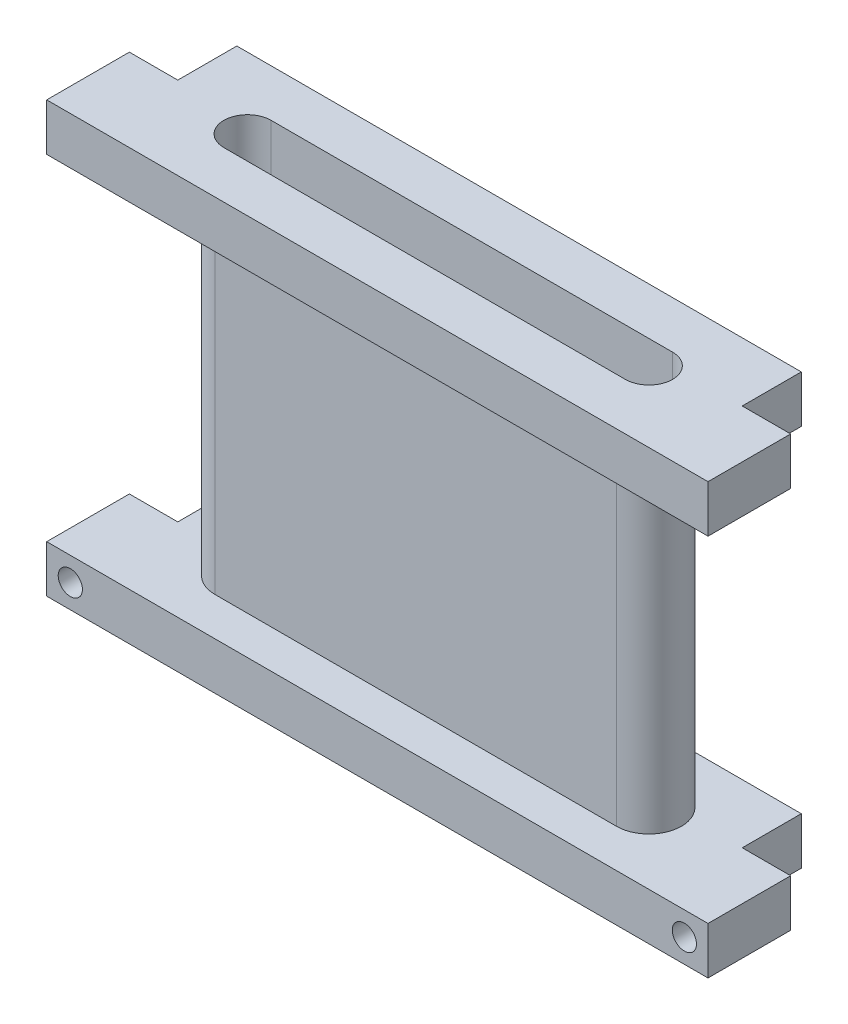
from build123d import *

# Parameters (mm, degrees)
SKETCH1_W                        = 56
SKETCH1_H                        = 8.750000002
BOSS_EXTRUDE1_DEPTH              = 4
BOSS_EXTRUDE2_DEPTH              = 28.4
SKETCH3_W                        = 56
SKETCH3_H                        = 12
BOSS_EXTRUDE3_DEPTH              = 4
SKETCH4_W                        = 56
SKETCH4_H                        = 4
BOSS_EXTRUDE4_DEPTH              = 3.249999998
CUT_EXTRUDE1_REACH               = 38.4
SKETCH5_W                        = 4.100000004
SKETCH5_H                        = 5
CUT_EXTRUDE2_REACH               = 38.4
SKETCH6_W                        = 4.100000004
SKETCH6_H                        = 5.000000001
SKETCH7_W                        = 4.100000004
SKETCH7_H                        = 5.000000001
CUT_EXTRUDE3_DEPTH               = 37.4
SKETCH8_W                        = 4.100000004
SKETCH8_H                        = 5
CUT_EXTRUDE4_DEPTH               = 37.4
CUT_EXTRUDE5_DEPTH               = 37.4
F_2_05_2_05_DIAMETER_HOLE1_D     = 2.05
F_2_05_2_05_DIAMETER_HOLE1_DEPTH = 4
F_2_05_2_05_DIAMETER_HOLE1_TIP   = 0.615882135


with BuildPart() as part:
    # Sketch1 → Boss-Extrude1 (new body)
    with BuildSketch(Plane(origin=(0, 0, 0), x_dir=(1, 0, 0), z_dir=(0, 1, 0))):
        with Locations((0, 1.624999999)):
            Rectangle(SKETCH1_W, SKETCH1_H)
    extrude(amount=-BOSS_EXTRUDE1_DEPTH)

    # Sketch2 → Boss-Extrude2 (add)
    with BuildSketch(Plane(origin=(0, 0, 0), x_dir=(-1, 0, 0), z_dir=(0, 1, 0))):
        with BuildLine():
            Line((-17, 2.75), (17, 2.75))
            ThreePointArc((17, 2.75), (19.75, 0), (17, -2.75))
            Line((17, -2.75), (-17, -2.75))
            ThreePointArc((-17, -2.75), (-19.75, 0), (-17, 2.75))
        make_face()
    extrude(amount=BOSS_EXTRUDE2_DEPTH)

    # Sketch3 → Boss-Extrude3 (add)
    with BuildSketch(Plane.XZ.offset(-28.4)):
        Rectangle(SKETCH3_W, SKETCH3_H)
    extrude(amount=-BOSS_EXTRUDE3_DEPTH)

    # Sketch4 → Boss-Extrude4 (add)
    with BuildSketch(Plane.XY.offset(2.750000002)):
        with Locations((0, -2)):
            Rectangle(SKETCH4_W, SKETCH4_H)
    extrude(amount=BOSS_EXTRUDE4_DEPTH)

    # Sketch5 → Cut-Extrude1 (cut, up to next)
    with BuildSketch(Plane(origin=(0, 32.4, 0), x_dir=(-1, 0, 0), z_dir=(0, 1, 0)), mode=Mode.PRIVATE) as cut_extrude1_sk1:
        with Locations((25.949999998, -3.5)):
            Rectangle(SKETCH5_W, SKETCH5_H)
    cut_extrude1_tool1 = extrude(cut_extrude1_sk1.sketch, amount=-CUT_EXTRUDE1_REACH, mode=Mode.PRIVATE) & part.part
    add(cut_extrude1_tool1.solids().sort_by_distance((-25.95, 32.4, -3.5))[0], mode=Mode.SUBTRACT)

    # Sketch6 → Cut-Extrude2 (cut, up to next)
    with BuildSketch(Plane(origin=(0, 32.4, 0), x_dir=(-1, 0, 0), z_dir=(0, 1, 0)), mode=Mode.PRIVATE) as cut_extrude2_sk1:
        with Locations((-25.949999998, -3.499999999)):
            Rectangle(SKETCH6_W, SKETCH6_H)
    cut_extrude2_tool1 = extrude(cut_extrude2_sk1.sketch, amount=-CUT_EXTRUDE2_REACH, mode=Mode.PRIVATE) & part.part
    add(cut_extrude2_tool1.solids().sort_by_distance((25.95, 32.4, -3.5))[0], mode=Mode.SUBTRACT)

    # Sketch7 → Cut-Extrude3 (cut, through all)
    with BuildSketch(Plane.XZ.offset(4)):
        with Locations((25.949999998, -3.499999999)):
            Rectangle(SKETCH7_W, SKETCH7_H)
    extrude(amount=-CUT_EXTRUDE3_DEPTH, mode=Mode.SUBTRACT)

    # Sketch8 → Cut-Extrude4 (cut, through all)
    with BuildSketch(Plane.XZ.offset(4)):
        with Locations((-25.949999998, -3.5)):
            Rectangle(SKETCH8_W, SKETCH8_H)
    extrude(amount=-CUT_EXTRUDE4_DEPTH, mode=Mode.SUBTRACT)

    # Sketch9 → Cut-Extrude5 (cut, through all)
    with BuildSketch(Plane.XZ.offset(4)):
        with BuildLine():
            Line((-17, -2.000000002), (17, -2.000000002))
            ThreePointArc((17, -2.000000002), (19.000000002, 0), (17, 2.000000002))
            Line((17, 2.000000002), (-17, 2.000000002))
            ThreePointArc((-17, 2.000000002), (-19.000000002, 0), (-17, -2.000000002))
        make_face()
    extrude(amount=-CUT_EXTRUDE5_DEPTH, mode=Mode.SUBTRACT)

    # Ø2.05 (2.05) Diameter Hole1
    with Locations(Plane.XY.offset(6)):
        with Locations((26, -2), (-26, -2)):
            Hole(F_2_05_2_05_DIAMETER_HOLE1_D / 2, depth=F_2_05_2_05_DIAMETER_HOLE1_DEPTH)
            with Locations((0, 0, -(F_2_05_2_05_DIAMETER_HOLE1_DEPTH + F_2_05_2_05_DIAMETER_HOLE1_TIP / 2))):  # 118° drill point
                Cone(0, F_2_05_2_05_DIAMETER_HOLE1_D / 2, F_2_05_2_05_DIAMETER_HOLE1_TIP, mode=Mode.SUBTRACT)


solid = part.part
